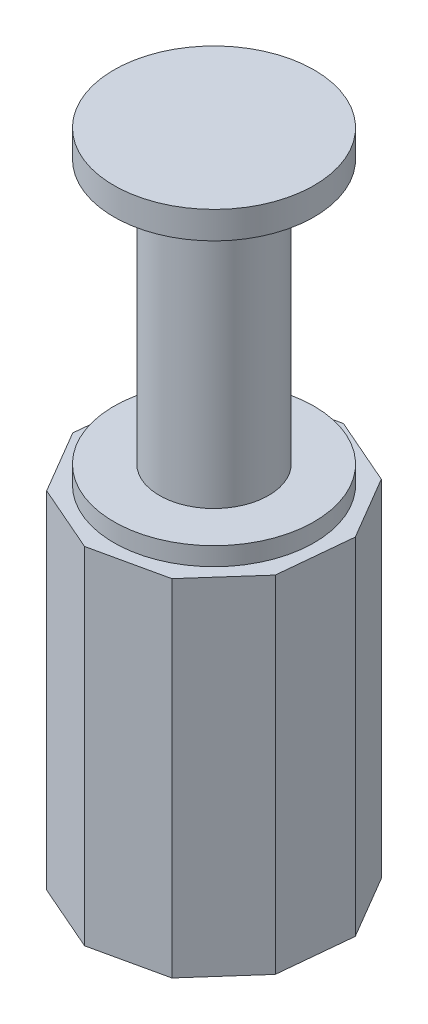
from build123d import *

# Parameters (mm, degrees)
EXTRUDE_2_DEPTH = 190


with BuildPart() as part:
    # Эскиз2 → Повернуть1 (revolve)
    with BuildSketch(Plane(origin=(0, 0, 0), x_dir=(0, 0, -1), z_dir=(1, 0, 0))):
        Polygon((0, 0), (55, 0), (55, 10), (30, 10), (30, 155), (55, 155), (55, 170), (0, 170), align=None)
    revolve(axis=Axis((0, -61.701185429, 0), (0, 1, 0)))

    # Эскиз3 → Бобышка-Вытянуть2 (add)
    with BuildSketch(Plane.XZ):
        Polygon((43.193084505, -48.718094896), (63.579717104, -14.025508632), (59.681058764, 26.024345221), (32.986264461, 56.133783734), (-6.308161704, 64.802024777), (-43.193084505, 48.718094896), (-63.579717104, 14.025508632), (-59.681058764, -26.024345221), (-32.986264461, -56.133783734), (6.308161704, -64.802024777), align=None)
    extrude(amount=EXTRUDE_2_DEPTH)


solid = part.part
